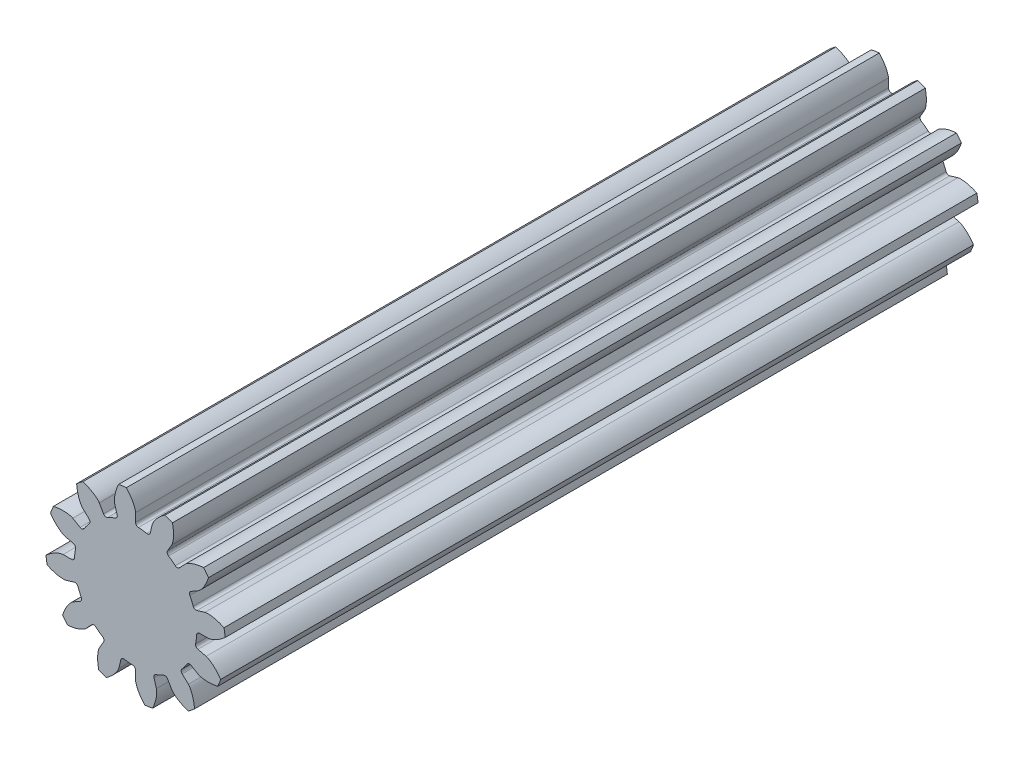
from build123d import *

# Parameters (mm, degrees)
SKETCH1_R                = 3.037416945
BOSS_EXTRUDE1_DEPTH      = 25.4
CUT_EXTRUDE1_START       = -26.4
CUT_EXTRUDE1_DEPTH       = 27.4
FILLET1_R                = 0.1016
CIRPATTERN1_COUNT        = 12
FILLET1_OF_CIRPATTERN1_R = 0.1016


with BuildPart() as part:
    # Sketch1 → Boss-Extrude1 (new body)
    with BuildSketch(Plane.XY):
        Circle(SKETCH1_R)
    extrude(amount=-BOSS_EXTRUDE1_DEPTH)

    # Sketch2 → Cut-Extrude1 (cut)
    with BuildSketch(Plane.XY.offset(CUT_EXTRUDE1_START)):
        with BuildLine():
            Line((2.446489962, 0), (2.061104356, 0))
            ThreePointArc((2.061104356, 0), (2.047253907, -0.238542669), (2.005888709, -0.473879365))
            Line((2.005888709, -0.473879365), (2.380950086, -0.562485401))
            add(Edge.make_bspline(
                [(2.380950086, -0.562485401), (2.382701529, -0.562938498), (2.387582821, -0.564323691), (2.396683048, -0.567392588), (2.411317489, -0.573029397), (2.429624514, -0.581126648), (2.452851304, -0.592625025), (2.479612415, -0.607478186), (2.508340697, -0.625145305), (2.53880884, -0.645785673), (2.568469824, -0.667608635), (2.597338174, -0.690498537), (2.625423092, -0.714295708), (2.658612339, -0.744267471), (2.697230224, -0.781782691), (2.740559213, -0.827842138), (2.78749351, -0.882626086), (2.825860346, -0.932045786), (2.851560706, -0.967405067), (2.866115042, -0.988304545), (2.870123576, -0.994128945)],
                knots=[0, 0, 0, 0, 0, 0.005376748, 0.015083688, 0.02853182, 0.046610139, 0.064854849, 0.092110525, 0.119476175, 0.146842495, 0.174208853, 0.201574955, 0.228941013, 0.256307345, 0.307035032, 0.361767351, 0.41649966, 0.471231936, 0.492236381, 0.492236381, 0.492236381, 0.492236381, 0.492236381], degree=4))
            ThreePointArc((2.870123576, -0.994128945), (2.995301628, -0.504053427), (3.037416945, 0))
            ThreePointArc((3.037416945, 0), (3.03351026, 0.154003897), (3.021800255, 0.307611638))
            add(Edge.make_bspline(
                [(2.446489962, 0), (2.44829866, 3.8275e-05), (2.453367662, 0.000264076), (2.462929686, 0.001158478), (2.478468068, 0.003279599), (2.498146342, 0.006950866), (2.523394554, 0.012801015), (2.552853721, 0.021103481), (2.584874331, 0.031692239), (2.619271788, 0.044774574), (2.653155606, 0.059193399), (2.686513329, 0.074832821), (2.719317203, 0.091535329), (2.758508298, 0.113073454), (2.804716957, 0.140704824), (2.857474961, 0.175568373), (2.915747585, 0.218093783), (2.964448941, 0.257368439), (2.997590444, 0.285871563), (3.016559989, 0.302864894), (3.021800255, 0.307611638)],
                knots=[0, 0, 0, 0, 0, 0.005376748, 0.015083688, 0.02853182, 0.046610139, 0.064854849, 0.092110525, 0.119476175, 0.146842495, 0.174208853, 0.201574955, 0.228941013, 0.256307345, 0.307035032, 0.361767351, 0.41649966, 0.471231936, 0.492236381, 0.492236381, 0.492236381, 0.492236381, 0.492236381], degree=4))
        make_face()
    cut_extrude1 = extrude(amount=CUT_EXTRUDE1_DEPTH, mode=Mode.SUBTRACT)

    # Fillet1
    fillet1_edges = [part.edges().sort_by_distance(p)[0] for p in [
        (2.061104356, 0, -12.7),
        (2.005888709, -0.473879365, -12.7),
    ]]
    fillet(fillet1_edges, radius=FILLET1_R)

    # CirPattern1: Cut-Extrude1 ×12 about axis
    cirpattern1_axis = Axis((0, 0, -25.4), (0, 0, 1))
    for i in range(1, CIRPATTERN1_COUNT):
        add(cut_extrude1.rotate(cirpattern1_axis, i * 360 / CIRPATTERN1_COUNT), mode=Mode.SUBTRACT)

    # Fillet1 of CirPattern1
    fillet1_of_cirpattern1_edges = [part.edges().sort_by_distance(p)[0] for p in [
        (1.784968732, 1.030552178, -12.7),
        (1.974090262, 0.592552786, -12.7),
        (1.030552178, 1.784968732, -12.7),
        (1.413335923, 1.500210896, -12.7),
        (0, 2.061104356, -12.7),
        (0.473879365, 2.005888709, -12.7),
        (-1.030552178, 1.784968732, -12.7),
        (-0.592552786, 1.974090262, -12.7),
        (-1.784968732, 1.030552178, -12.7),
        (-1.500210896, 1.413335923, -12.7),
        (-2.061104356, 0, -12.7),
        (-2.005888709, 0.473879365, -12.7),
        (-1.784968732, -1.030552178, -12.7),
        (-1.974090262, -0.592552786, -12.7),
        (-1.030552178, -1.784968732, -12.7),
        (-1.413335923, -1.500210896, -12.7),
        (0, -2.061104356, -12.7),
        (-0.473879365, -2.005888709, -12.7),
        (1.030552178, -1.784968732, -12.7),
        (0.592552786, -1.974090262, -12.7),
        (1.784968732, -1.030552178, -12.7),
        (1.500210896, -1.413335923, -12.7),
    ]]
    fillet(fillet1_of_cirpattern1_edges, radius=FILLET1_OF_CIRPATTERN1_R)


solid = part.part
